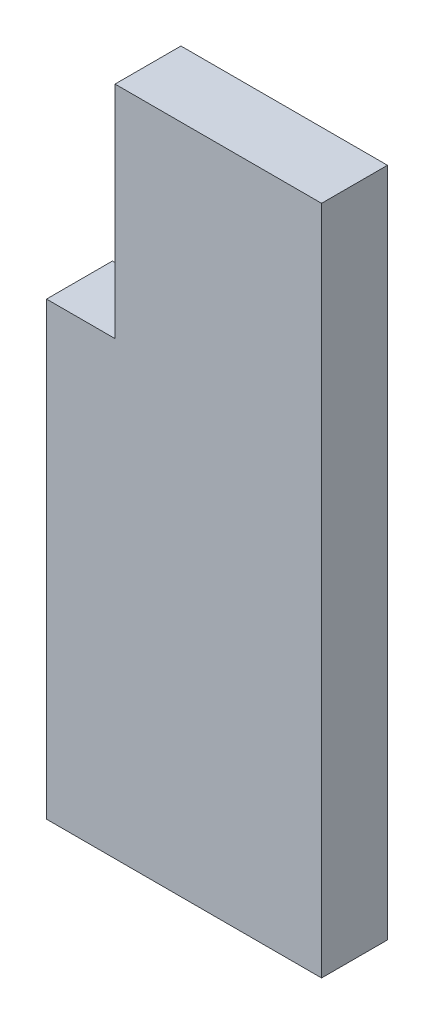
from build123d import *

# Parameters (mm, degrees)
BOSS_EXTRUDE1_DEPTH = 3.175
SKETCH2_W           = 43.35
SKETCH2_H           = 32.32
CUT_EXTRUDE1_DEPTH  = 3.175


with BuildPart() as part:
    # Sketch1 → Boss-Extrude1 (new body)
    with BuildSketch(Plane.XY):
        Polygon((0, 21.7), (0, 0), (56.6, 0), (56.6, 21.7), (53.3, 21.7), (53.3, 32.32), (43.35, 32.32), (43.35, 15.66), (13.25, 15.66), (13.25, 32.32), (3.3, 32.32), (3.3, 21.7), align=None)
    extrude(amount=BOSS_EXTRUDE1_DEPTH)

    # Sketch2 → Cut-Extrude1 (cut)
    with BuildSketch(Plane.XY.offset(3.175)):
        with Locations((34.925, 16.16)):
            Rectangle(SKETCH2_W, SKETCH2_H)
    extrude(amount=-CUT_EXTRUDE1_DEPTH, mode=Mode.SUBTRACT)


solid = part.part
